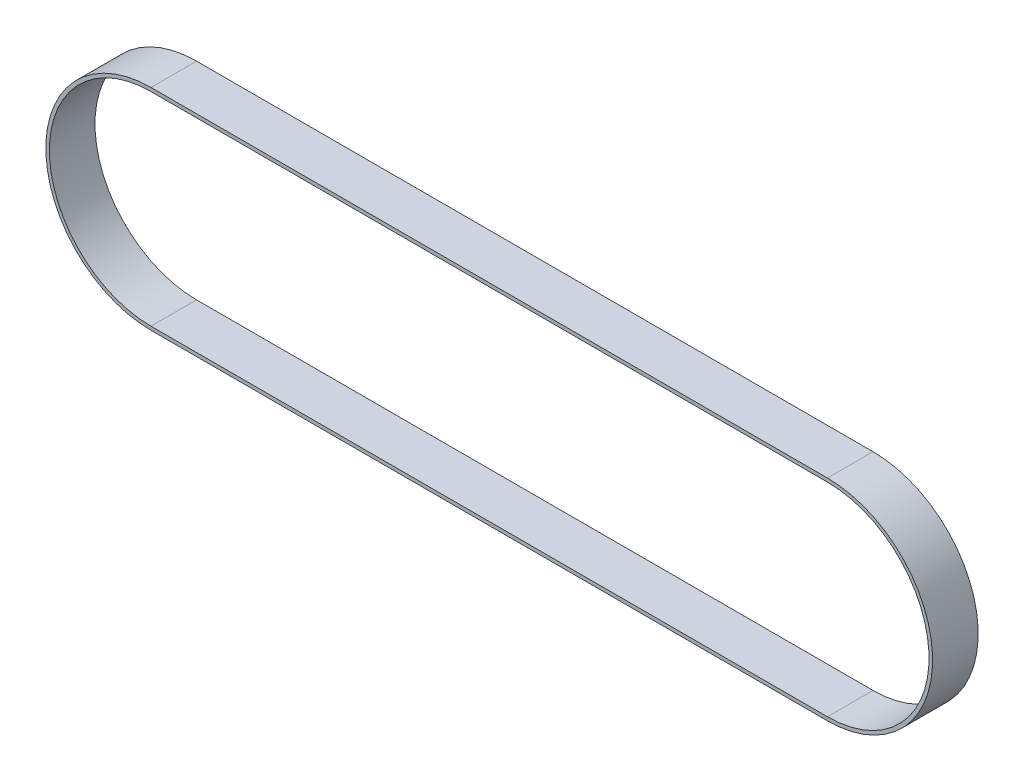
from build123d import *

# Parameters (mm, degrees)
BOSS_EXTRUDE1_DEPTH = 15


with BuildPart() as part:
    # Sketch1 → Boss-Extrude1 (new body)
    with BuildSketch(Plane.XY):
        with BuildLine():
            Line((0, 34.5948), (222.5548, 34.5948))
            ThreePointArc((222.5548, 34.5948), (257.1496, 0), (222.5548, -34.5948))
            Line((222.5548, -34.5948), (0, -34.5948))
            ThreePointArc((0, -34.5948), (-34.5948, 0), (0, 34.5948))
        make_face()
        with BuildLine():
            Line((0, 33.4264), (222.5548, 33.4264))
            ThreePointArc((222.5548, 33.4264), (255.9812, 0), (222.5548, -33.4264))
            Line((222.5548, -33.4264), (0, -33.4264))
            ThreePointArc((0, -33.4264), (-33.4264, 0), (0, 33.4264))
        make_face(mode=Mode.SUBTRACT)
    extrude(amount=BOSS_EXTRUDE1_DEPTH)


solid = part.part
